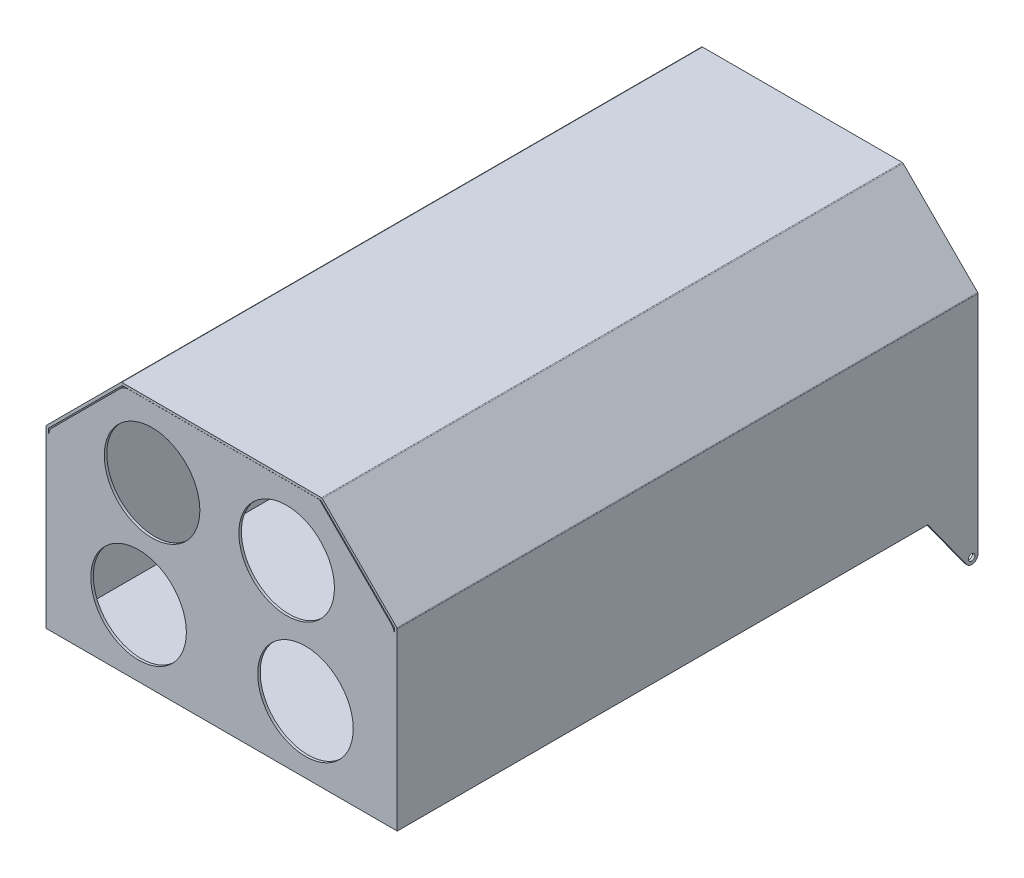
from build123d import *

# Parameters (mm, degrees)
BOSS_EXTRUDE1_DEPTH = 463
SHELL2_T            = -2
SKETCH2_R           = 2.55
BOSS_EXTRUDE2_DEPTH = 2
SKETCH4_R           = 5.25
BOSS_EXTRUDE3_DEPTH = 2
BOSS_EXTRUDE4_DEPTH = 2
SKETCH6_R           = 38.1
CUT_EXTRUDE1_DEPTH  = 2


with BuildPart() as part:
    # Sketch1 → Boss-Extrude1 (new body)
    with BuildSketch(Plane.XY):
        with BuildLine():
            Line((-169.657845697, 59.751021298), (-110.243632135, 119.16523486))
            ThreePointArc((-110.243632135, 119.16523486), (-109.919208786, 119.382007611), (-109.536525354, 119.458128079))
            Line((-109.536525354, 119.458128079), (49.635047521, 119.458128079))
            ThreePointArc((49.635047521, 119.458128079), (50.017730954, 119.382007611), (50.342154303, 119.16523486))
            Line((50.342154303, 119.16523486), (109.756367865, 59.751021298))
            ThreePointArc((109.756367865, 59.751021298), (109.973140616, 59.426597949), (110.049261084, 59.043914516))
            Line((110.049261084, 59.043914516), (110.049261084, -80.540871921))
            ThreePointArc((110.049261084, -80.540871921), (110.048968191, -80.541579028), (110.048261084, -80.541871921))
            Line((110.048261084, -80.541871921), (-169.949738916, -80.541871921))
            ThreePointArc((-169.949738916, -80.541871921), (-169.950446023, -80.541579028), (-169.950738916, -80.540871921))
            Line((-169.950738916, -80.540871921), (-169.950738916, 59.043914516))
            ThreePointArc((-169.950738916, 59.043914516), (-169.874618449, 59.426597949), (-169.657845697, 59.751021298))
        make_face()
    extrude(amount=BOSS_EXTRUDE1_DEPTH)

    # Shell2
    shell2_openings = [part.faces().sort_by_distance(p)[0] for p in [
        (-29.950738916, 32.739133998, 463),
    ]]
    offset(amount=SHELL2_T, openings=shell2_openings, kind=Kind.INTERSECTION)

    # Sketch2 → Boss-Extrude2 (add)
    with BuildSketch(Plane(origin=(110.049261084, 0, 0), x_dir=(0, 0, -1), z_dir=(1, 0, 0))):
        with BuildLine():
            Line((-40, -80.540871921), (-9.025530914, -123.506525452))
            ThreePointArc((-9.025530914, -123.506525452), (-3.439175629, -125.291011633), (0, -120.540871921))
            Line((0, -120.540871921), (0, -80.540871921))
            Line((0, -80.540871921), (-40, -80.540871921))
        make_face()
        with Locations((-5, -120.540871921)):
            Circle(SKETCH2_R, mode=Mode.SUBTRACT)
    boss_extrude2 = extrude(amount=-BOSS_EXTRUDE2_DEPTH)

    # Mirror1: Boss-Extrude2 across plane
    add(boss_extrude2.mirror(Plane(origin=(-29.950738916, 0, 0), x_dir=(0, 0, 1), z_dir=(1, 0, 0))))

    # Sketch4 → Boss-Extrude3 (add)
    with BuildSketch(Plane(origin=(-49.950738916, 0, 0), x_dir=(0, 0, -1), z_dir=(1, 0, 0))):
        with BuildLine():
            Line((-352.326976552, -122.966309209), (-377.571249485, -80.540871921))
            Line((-377.571249485, -80.540871921), (-309.673952471, -80.540871921))
            Line((-309.673952471, -80.540871921), (-336.899509657, -123.589322478))
            ThreePointArc((-336.899509657, -123.589322478), (-344.793097516, -127.731489821), (-352.326976552, -122.966309209))
        make_face()
        with Locations((-344.43340661, -118.824585544)):
            Circle(SKETCH4_R, mode=Mode.SUBTRACT)
    boss_extrude3 = extrude(amount=-BOSS_EXTRUDE3_DEPTH)

    # Mirror2: Boss-Extrude3 across plane
    add(boss_extrude3.mirror(Plane(origin=(-29.950738916, 0, 0), x_dir=(0, 0, 1), z_dir=(1, 0, 0))))

    # Sketch5 → Boss-Extrude4 (add)
    with BuildSketch(Plane.XY.offset(463)):
        with BuildLine():
            Line((-165.021806728, 60.299996742), (-110.879671104, 114.442132366))
            ThreePointArc((-110.879671104, 114.442132366), (-107.635437616, 116.609859879), (-103.808603293, 117.371064554))
            Line((-103.808603293, 117.371064554), (48.049261084, 117.371064554))
            Line((48.049261084, 117.371064554), (105.120328896, 60.299996742))
            ThreePointArc((105.120328896, 60.299996742), (107.288056409, 57.055763254), (108.049261084, 53.22892893))
            Line((108.049261084, 53.22892893), (108.049261084, -78.541871921))
            Line((108.049261084, -78.541871921), (-167.950738916, -78.541871921))
            Line((-167.950738916, -78.541871921), (-167.950738916, 53.22892893))
            ThreePointArc((-167.950738916, 53.22892893), (-167.189534241, 57.055763254), (-165.021806728, 60.299996742))
        make_face()
    extrude(amount=-BOSS_EXTRUDE4_DEPTH)

    # Sketch6 → Cut-Extrude1 (cut)
    with BuildSketch(Plane.XY.offset(463)):
        with Locations((36.895099285, -27.454834831)):
            Circle(SKETCH6_R)
        with Locations((-96.144422598, -27.454834831)):
            Circle(SKETCH6_R)
        with Locations((-85.383873034, 62.216411536)):
            Circle(SKETCH6_R)
        with Locations((21.895545347, 62.216411536)):
            Circle(SKETCH6_R)
    extrude(amount=-CUT_EXTRUDE1_DEPTH, mode=Mode.SUBTRACT)


solid = part.part
